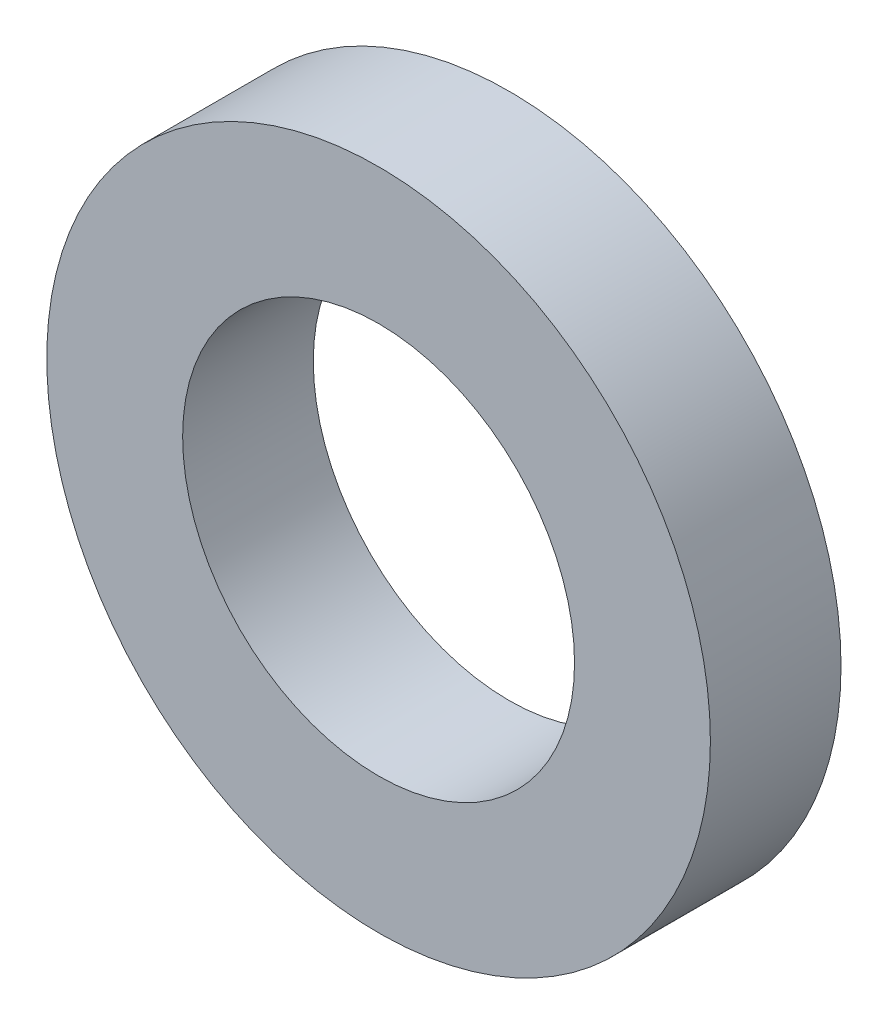
from build123d import *

# Parameters (mm, degrees)
SKETCH1_R           = 2.54
SKETCH1_R_2         = 1.5
BOSS_EXTRUDE1_DEPTH = 0.5


with BuildPart() as part:
    # Sketch1 → Boss-Extrude1 (new body, symmetric)
    with BuildSketch(Plane.XY):
        Circle(SKETCH1_R)
        Circle(SKETCH1_R_2, mode=Mode.SUBTRACT)
    extrude(amount=BOSS_EXTRUDE1_DEPTH, both=True)


solid = part.part
